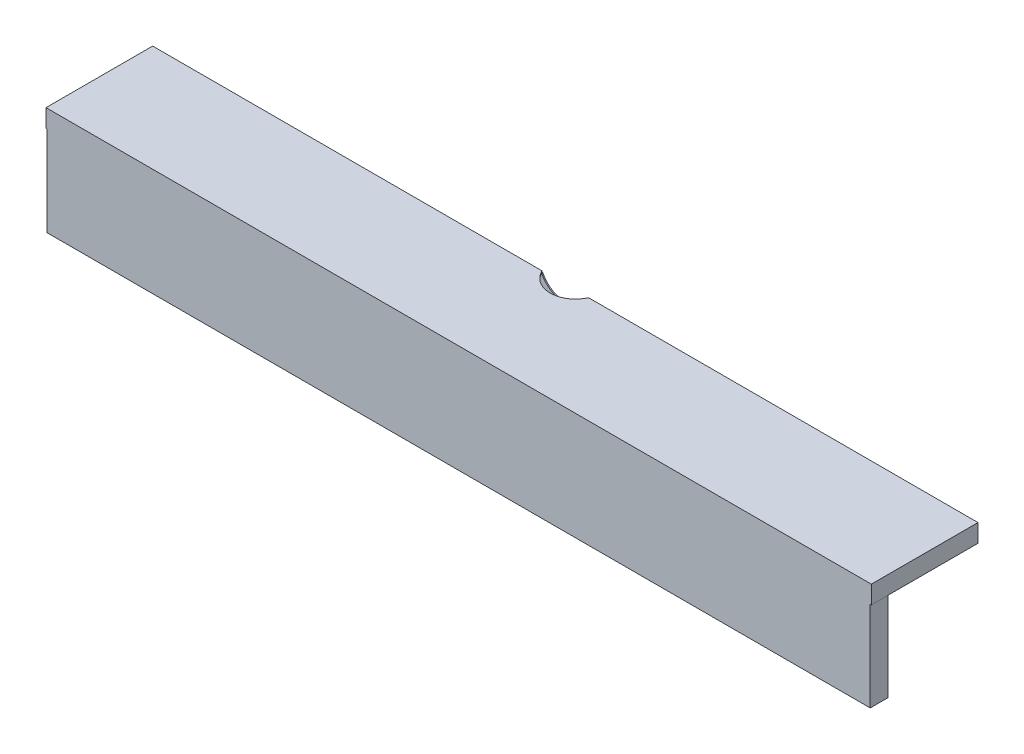
from build123d import *

# Parameters (mm, degrees)
CROQUIS1_W              = 735
CROQUIS1_H              = 95
SALIENTE_EXTRUIR1_DEPTH = 1
SALIENTE_EXTRUIR2_DEPTH = 15
CROQUIS3_R              = 22.5
CORTAR_EXTRUIR1_DEPTH   = 1
CROQUIS4_R              = 22.5
CORTAR_EXTRUIR2_DEPTH   = 1
CROQUIS5_W              = 1
CROQUIS5_H              = 15
SALIENTE_EXTRUIR3_DEPTH = 15
SALIENTE_EXTRUIR4_REACH = 394.5
CROQUIS6_W              = 15
CROQUIS6_H              = 1
CORTAR_EXTRUIR3_REACH   = 18
CROQUIS8_W              = 1
CROQUIS8_H              = 95
SALIENTE_EXTRUIR5_DEPTH = 733
SALIENTE_EXTRUIR6_DEPTH = 15
CROQUIS10_R             = 1.5
SALIENTE_EXTRUIR7_DEPTH = 3.5


with BuildPart() as part:
    # Croquis1 → Saliente-Extruir1 (new body)
    with BuildSketch(Plane(origin=(0, 0, 0), x_dir=(1, 0, 0), z_dir=(0, 1, 0))):
        Rectangle(CROQUIS1_W, CROQUIS1_H)
    extrude(amount=SALIENTE_EXTRUIR1_DEPTH)

    # Croquis2 → Saliente-Extruir2 (add)
    with BuildSketch(Plane.XZ):
        Polygon((366.5, 47.5), (366.5, -46.5), (-366.5, -46.5), (-366.5, 47.5), (-367.5, 47.5), (-367.5, -47.5), (367.5, -47.5), (367.5, 47.5), align=None)
    extrude(amount=SALIENTE_EXTRUIR2_DEPTH)

    # Croquis3 → Cortar-Extruir1 (cut)
    with BuildSketch(Plane(origin=(0, 0, -47.5), x_dir=(-1, 0, 0), z_dir=(0, 0, -1))):
        with Locations((0, 10)):
            Circle(CROQUIS3_R)
    extrude(amount=-CORTAR_EXTRUIR1_DEPTH, mode=Mode.SUBTRACT)

    # Croquis4 → Cortar-Extruir2 (cut)
    with BuildSketch(Plane(origin=(0, 1, 0), x_dir=(1, 0, 0), z_dir=(0, 1, 0))):
        with Locations((0, 56.5)):
            Circle(CROQUIS4_R)
    extrude(amount=-CORTAR_EXTRUIR2_DEPTH, mode=Mode.SUBTRACT)

    # Croquis5 → Saliente-Extruir3 (add)
    with BuildSketch(Plane.XZ):
        with Locations((-25.5, -39)):
            Rectangle(CROQUIS5_W, CROQUIS5_H)
        with Locations((25.5, -39)):
            Rectangle(CROQUIS5_W, CROQUIS5_H)
    extrude(amount=SALIENTE_EXTRUIR3_DEPTH)

    # Croquis6 → Saliente-Extruir4 (add, up to next)
    with BuildSketch(Plane(origin=(-25, 0, 0), x_dir=(0, 0, -1), z_dir=(1, 0, 0)), mode=Mode.PRIVATE) as saliente_extruir4_sk1:
        with Locations((39, -14.5)):
            Rectangle(CROQUIS6_W, CROQUIS6_H)
    saliente_extruir4_tool1 = extrude(saliente_extruir4_sk1.sketch, amount=SALIENTE_EXTRUIR4_REACH, mode=Mode.PRIVATE) - part.part
    add(saliente_extruir4_tool1.solids().sort_by_distance((-25, -14.5, -39))[0])

    # Croquis7 → Cortar-Extruir3 (cut, up to next)
    with BuildSketch(Plane.XZ.offset(15), mode=Mode.PRIVATE) as cortar_extruir3_sk1:
        with BuildLine():
            Line((-6.54864521, -34.909050446), (6.54864521, -34.909050446))
            ThreePointArc((6.54864521, -34.909050446), (8.601520455, -36.961925691), (6.54864521, -39.014800936))
            Line((6.54864521, -39.014800936), (-6.54864521, -39.014800936))
            ThreePointArc((-6.54864521, -39.014800936), (-8.601520455, -36.961925691), (-6.54864521, -34.909050446))
        make_face()
    cortar_extruir3_tool1 = extrude(cortar_extruir3_sk1.sketch, amount=-CORTAR_EXTRUIR3_REACH, mode=Mode.PRIVATE) & part.part
    add(cortar_extruir3_tool1.solids().sort_by_distance((0, -15, -36.961926))[0], mode=Mode.SUBTRACT)

    # Croquis8 → Saliente-Extruir5 (add)
    with BuildSketch(Plane.ZY.offset(-366.5)):
        with Locations((47, -47.5)):
            Rectangle(CROQUIS8_W, CROQUIS8_H)
    extrude(amount=SALIENTE_EXTRUIR5_DEPTH)

    # Croquis9 → Saliente-Extruir6 (add)
    with BuildSketch(Plane(origin=(0, 0, 46.5), x_dir=(-1, 0, 0), z_dir=(0, 0, -1))):
        Polygon((-366.5, -15.890406143), (-365.5, -15.890406143), (-365.5, -94), (365.5, -94), (365.5, -15.890406143), (366.5, -15.890406143), (366.5, -95), (-366.5, -95), align=None)
    extrude(amount=SALIENTE_EXTRUIR6_DEPTH)

    # Croquis10 → Saliente-Extruir7 (add)
    with BuildSketch(Plane.ZY.offset(366.5)):
        with Locations((39.5, -89)):
            Circle(CROQUIS10_R)
    extrude(amount=SALIENTE_EXTRUIR7_DEPTH)


solid = part.part
